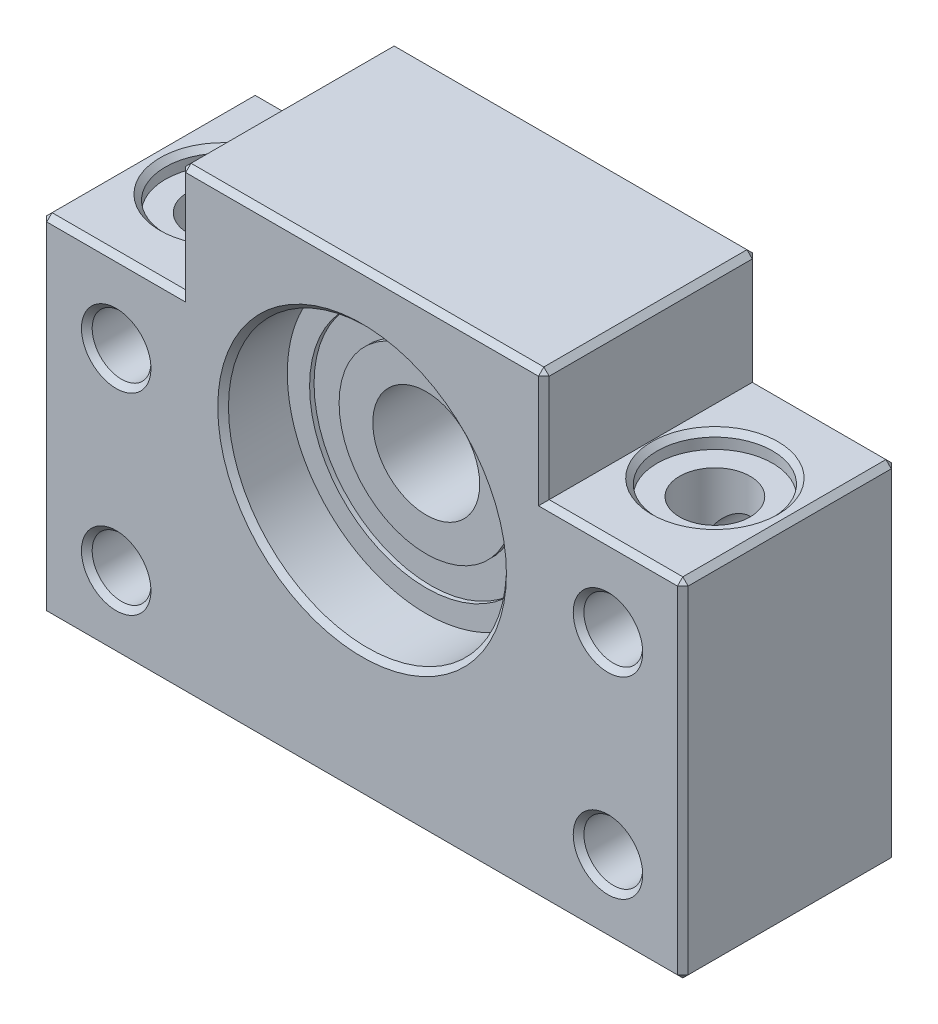
from build123d import *

# Parameters (mm, degrees)
SKETCH1_R           = 13
BOSS_EXTRUDE1_DEPTH = 10
SKETCH2_R           = 2.75
CUT_EXTRUDE1_DEPTH  = 21
SKETCH3_R           = 3.3
CUT_EXTRUDE2_DEPTH  = 33.5
SKETCH4_R           = 5.4
CUT_EXTRUDE3_DEPTH  = 1.5
CHAMFER1_SIZE       = 0.5


with BuildPart() as part:
    # Sketch1 → Boss-Extrude1 (new body, symmetric)
    with BuildSketch(Plane.XY):
        Polygon((17, 18), (-17, 18), (-17, 7.5), (-30, 7.5), (-30, -25), (30, -25), (30, 7.5), (17, 7.5), align=None)
        Circle(SKETCH1_R, mode=Mode.SUBTRACT)
    extrude(amount=BOSS_EXTRUDE1_DEPTH, both=True)

    # Sketch2 → Cut-Extrude1 (cut, through all)
    with BuildSketch(Plane.XY.offset(10)):
        with Locations((-23, 0)):
            Circle(SKETCH2_R)
        with Locations((-23, -18)):
            Circle(SKETCH2_R)
        with Locations((23, -18)):
            Circle(SKETCH2_R)
        with Locations((23, 0)):
            Circle(SKETCH2_R)
    extrude(amount=-CUT_EXTRUDE1_DEPTH, mode=Mode.SUBTRACT)

    # Sketch3 → Cut-Extrude2 (cut, through all)
    with BuildSketch(Plane(origin=(0, 7.5, 0), x_dir=(1, 0, 0), z_dir=(0, 1, 0))):
        with Locations((-23, 0)):
            Circle(SKETCH3_R)
        with Locations((23, 0)):
            Circle(SKETCH3_R)
    extrude(amount=-CUT_EXTRUDE2_DEPTH, mode=Mode.SUBTRACT)

    # Sketch4 → Cut-Extrude3 (cut)
    with BuildSketch(Plane(origin=(0, 7.5, 0), x_dir=(1, 0, 0), z_dir=(0, 1, 0))):
        with Locations((-23, 0)):
            Circle(SKETCH4_R)
        with Locations((23, 0)):
            Circle(SKETCH4_R)
    extrude(amount=-CUT_EXTRUDE3_DEPTH, mode=Mode.SUBTRACT)

    # Chamfer1
    chamfer1_edges = [part.edges().sort_by_distance(p)[0] for p in [
        (-30, -8.75, 10),
        (-23.5, 7.5, -10),
        (-17, 12.75, -10),
        (0, -25, 10),
        (-17, 18, 0),
        (17, 18, 0),
        (30, 7.5, 0),
        (30, -25, 0),
        (-30, -25, 0),
        (-30, 7.5, 0),
        (30, -8.75, 10),
        (23.5, 7.5, 10),
        (-13, 0, -10),
        (-13, 0, 10),
        (17, 12.75, 10),
        (0, 18, 10),
        (-25.75, 0, -10),
        (-25.75, 0, 10),
        (-25.75, -18, -10),
        (-25.75, -18, 10),
        (20.25, -18, -10),
        (20.25, -18, 10),
        (20.25, 0, -10),
        (20.25, 0, 10),
        (-17, 12.75, 10),
        (-28.4, 7.5, 0),
        (-23.5, 7.5, 10),
        (17.6, 7.5, 0),
        (0, 18, -10),
        (17, 12.75, -10),
        (23.5, 7.5, -10),
        (30, -8.75, -10),
        (0, -25, -10),
        (-30, -8.75, -10),
    ]]
    chamfer(chamfer1_edges, length=CHAMFER1_SIZE)


with BuildPart() as body_2:
    # Sketch5 → Revolve1 (revolve)
    with BuildSketch(Plane(origin=(0, 0, 0), x_dir=(1, 0, 0), z_dir=(0, 1, 0))):
        Polygon((-13, 4), (-10.911412894, 4), (-10.911412894, 3.582423173), (-8.151084393, 3.582423173), (-8.151084393, 4), (-5, 4), (-5, 0), (-13, 0), align=None)
    revolve(axis=Axis((0, 0, 0), (0, 0, -1)))

    # Mirror2: body 2 across plane


with BuildPart() as body_2_1:
    add(body_2.part)
    add(body_2.part.mirror(Plane(origin=(-13, 0, 0), x_dir=(1, 0, 0), z_dir=(0, 0, -1))))


solid = Compound([part.part, body_2_1.part])
